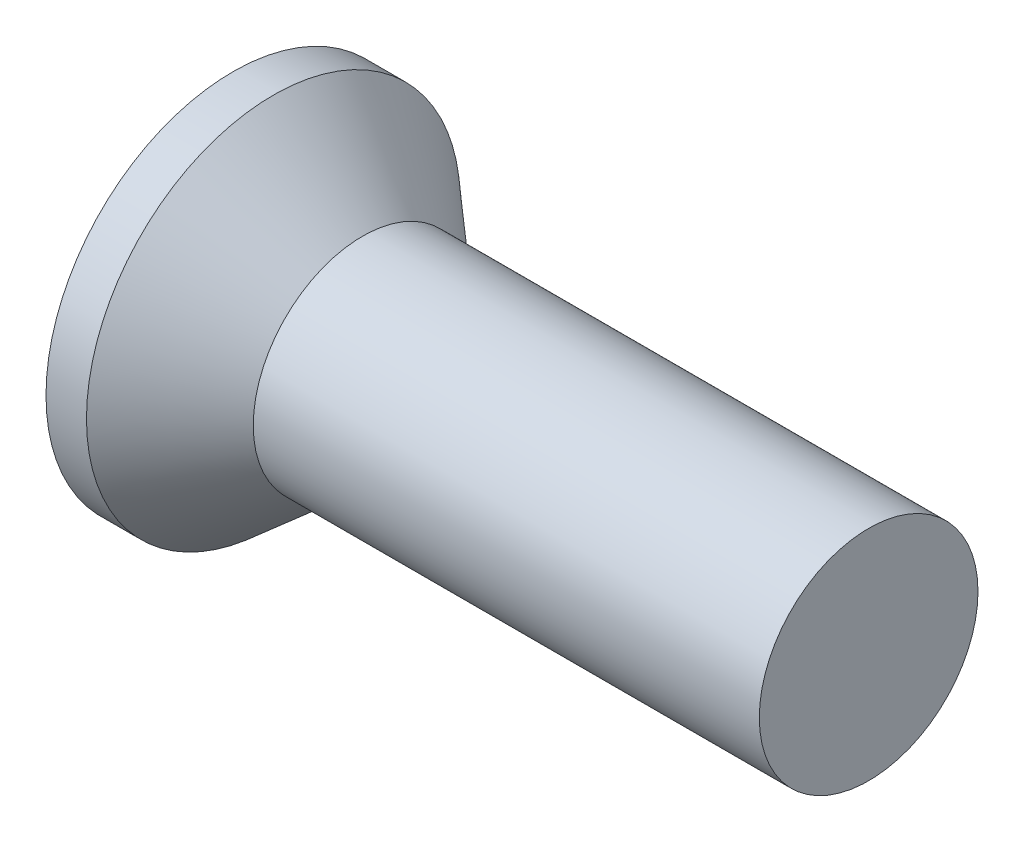
from build123d import *

# Parameters (mm, degrees)
SKETCH3_W         = 0.6858
SKETCH3_H         = 3.048
SKETCH4_W         = 0.3429
SKETCH4_H         = 0.3429
CIRPATTERN1_COUNT = 2
CIRPATTERN1_ANGLE = 90


with BuildPart() as part:
    # BodySke → Base-Revolve (revolve)
    with BuildSketch(Plane.XY):
        Polygon((0, 0), (0, 1.8669), (0.404209595, 1.8669), (1.2954, 1.0922), (6.35, 1.0922), (6.35, 0), align=None)
    revolve(axis=Axis((-6.35, 0, 0), (1, 0, 0)))

    # Sketch3 → Cross section 0
    with BuildSketch(Plane.ZY):
        Rectangle(SKETCH3_W, SKETCH3_H)
    # Sketch4 → Cross section 1
    with BuildSketch(Plane.ZY.offset(-1.6764)):
        Rectangle(SKETCH4_W, SKETCH4_H)
    cross = loft(mode=Mode.SUBTRACT)

    # CirPattern1: Cross ×2 about axis
    cirpattern1_axis = Axis((0, 0, 0), (1, 0, 0))
    for i in range(1, CIRPATTERN1_COUNT):
        add(cross.rotate(cirpattern1_axis, i * CIRPATTERN1_ANGLE / (CIRPATTERN1_COUNT - 1)), mode=Mode.SUBTRACT)


solid = part.part
